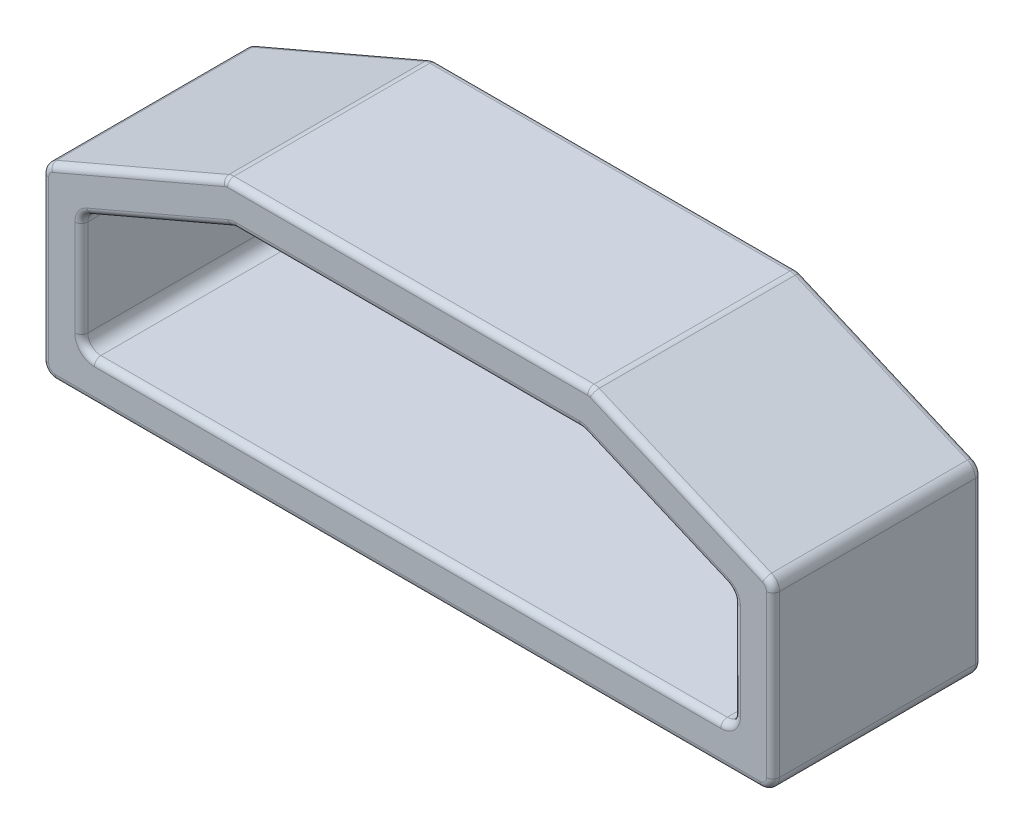
from build123d import *

# Parameters (mm, degrees)
BOSS_EXTRUDE1_DEPTH = 8
FILLET1_R           = 0.5
FILLET2_R           = 0.25


with BuildPart() as part:
    # Sketch1 → Boss-Extrude1 (new body)
    with BuildSketch(Plane.XY):
        Polygon((14, 0), (-14, 0), (-14, 7), (-7, 10), (7, 10), (14, 7), align=None)
        Polygon((12.5, 1.5), (-12.5, 1.5), (-12.5, 6.010905763), (-6.692113447, 8.5), (6.692113447, 8.5), (12.5, 6.010905763), align=None, mode=Mode.SUBTRACT)
    extrude(amount=BOSS_EXTRUDE1_DEPTH)

    # Fillet1
    fillet1_edges = [part.edges().sort_by_distance(p)[0] for p in [
        (14, 0, 4),
        (-14, 0, 4),
        (-14, 7, 4),
        (-7, 10, 4),
        (7, 10, 4),
        (14, 7, 4),
        (12.5, 1.5, 4),
        (12.5, 6.010905763, 4),
        (6.692113447, 8.5, 4),
        (-6.692113447, 8.5, 4),
        (-12.5, 6.010905763, 4),
        (-12.5, 1.5, 4),
    ]]
    fillet(fillet1_edges, radius=FILLET1_R)

    # Fillet2
    fillet2_edges = [part.edges().sort_by_distance(p)[0] for p in [
        (0, 1.5, 0),
        (0, 1.5, 8),
        (12.5, 3.840603842, 0),
        (12.5, 3.840603842, 8),
        (9.491701947, 7.300176357, 0),
        (9.491701947, 7.300176357, 8),
        (0, 8.5, 0),
        (0, 8.5, 8),
        (-9.491701947, 7.300176357, 0),
        (-9.491701947, 7.300176357, 8),
        (-12.5, 3.840603842, 0),
        (-12.5, 3.840603842, 8),
        (10.395645224, 8.544723476, 0),
        (10.395645224, 8.544723476, 8),
        (14, 3.585150961, 0),
        (0, 0, 0),
        (-14, 3.585150961, 0),
        (-10.395645224, 8.544723476, 0),
        (0, 10, 0),
        (6.997904085, 9.989788861, 0),
        (-6.997904085, 9.989788861, 0),
        (-13.917420546, 6.945547425, 0),
        (-13.853553391, 0.146446609, 0),
        (13.853553391, 0.146446609, 0),
        (13.917420546, 6.945547425, 0),
        (14, 3.585150961, 8),
        (0, 10, 8),
        (-10.395645224, 8.544723476, 8),
        (-14, 3.585150961, 8),
        (0, 0, 8),
        (6.997904085, 9.989788861, 8),
        (-6.997904085, 9.989788861, 8),
        (-13.917420546, 6.945547425, 8),
        (-13.853553391, 0.146446609, 8),
        (13.853553391, 0.146446609, 8),
        (13.917420546, 6.945547425, 8),
        (12.353553391, 1.646446609, 0),
        (12.353553391, 1.646446609, 8),
        (12.417420546, 5.956453188, 0),
        (12.417420546, 5.956453188, 8),
        (6.690017532, 8.489788861, 0),
        (6.690017532, 8.489788861, 8),
        (-6.690017532, 8.489788861, 0),
        (-6.690017532, 8.489788861, 8),
        (-12.417420546, 5.956453188, 0),
        (-12.417420546, 5.956453188, 8),
        (-12.353553391, 1.646446609, 0),
        (-12.353553391, 1.646446609, 8),
    ]]
    fillet(fillet2_edges, radius=FILLET2_R)


solid = part.part
